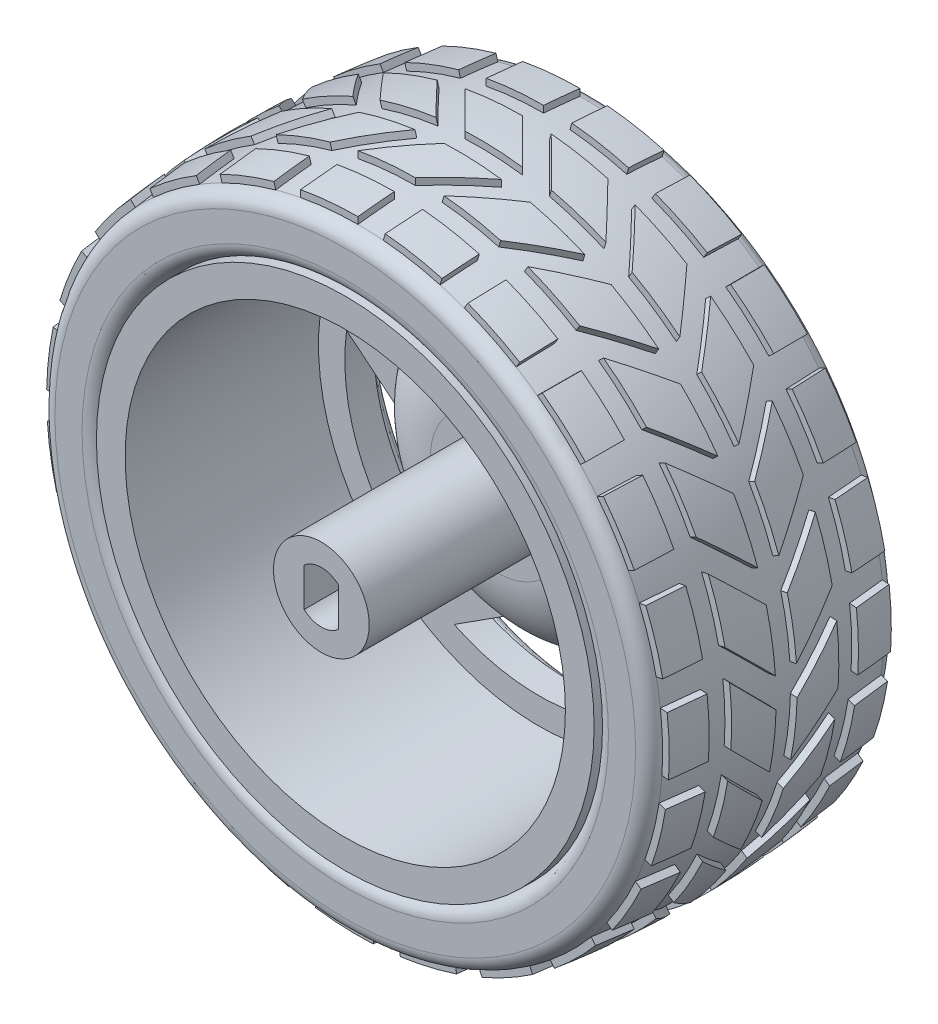
from build123d import *
from build123d.topology import SkipClean

# Parameters (mm, degrees)
CUT_EXTRUDE1_REACH  = 47.916
CIRPATTERN1_COUNT   = 5
SKETCH3_R           = 0.7500000000000007
CUT_EXTRUDE2_DEPTH  = 1
CIRPATTERN2_COUNT   = 5
SKETCH4_R           = 0.7499999999999999
BOSS_EXTRUDE1_DEPTH = 1.5
CIRPATTERN3_COUNT   = 4
FILLET1_R           = 0.75
CUT_EXTRUDE3_DEPTH  = 21.5
SKETCH6_R           = 23
SKETCH6_R_2         = 20.25
BOSS_EXTRUDE2_DEPTH = 3
FILLET2_R           = 0.5
BOSS_EXTRUDE3_REACH = 82.334
CIRPATTERN4_COUNT   = 23


with BuildPart() as part:
    # Sketch1 → Revolve1 (revolve)
    with BuildSketch(Plane(origin=(0, 0, 0), x_dir=(0, 0, -1), z_dir=(1, 0, 0)), mode=Mode.PRIVATE) as revolve1_sk:
        with BuildLine():
            Line((0, 0), (0, 5))
            Line((0, 5), (18.4, 5))
            Line((18.4, 5), (18.4, 7))
            ThreePointArc((18.4, 7), (19.547327493225943, 11.4232341109193), (22.700000000000006, 14.731106001084196))
            Line((22.700000000000006, 14.731106001084196), (22.700000000000006, 23))
            Line((22.700000000000006, 23), (2.500000000000002, 23))
            Line((2.500000000000002, 23), (2.500000000000002, 26))
            Line((2.500000000000002, 26), (29, 26))
            Line((29, 26), (28.999999999999996, 24.499999999999996))
            Line((28.999999999999996, 24.499999999999996), (28.200000000000003, 24.499999999999996))
            Line((28.200000000000003, 24.499999999999996), (28.200000000000003, 22.5))
            Line((28.200000000000003, 22.5), (25.700000000000003, 22.5))
            ThreePointArc((25.700000000000003, 22.5), (27.023630016085583, 20.96786686541544), (27.5, 19))
            Line((27.5, 19), (27.5, 12.1))
            ThreePointArc((27.5, 12.1), (23.893755415948608, 10.606244584051392), (22.4, 6.999999999999999))
            Line((22.4, 6.999999999999999), (22.400000000000002, 4.999999999999999))
            Line((22.400000000000002, 4.999999999999999), (24.5, 5))
            Line((24.5, 5), (24.5, 0))
            Line((24.5, 0), (0, 0))
        make_face()
    revolve(revolve1_sk.sketch.rotate(Axis((0, 0, 0), (0, 0, -1)), 90), axis=Axis((0, 0, 0), (0, 0, -1)))

    # Sketch2 → Cut-Extrude1 (cut, up to next)
    with BuildSketch(Plane(origin=(0, 0, -27.5), x_dir=(-1, 0, 0), z_dir=(0, 0, -1)), mode=Mode.PRIVATE) as cut_extrude1_sk1:
        with BuildLine():
            Line((-6.2937646876596895, 17.92731229315686), (-3.592234585008039, 19.89008880341997))
            Line((-3.592234585008039, 19.89008880341997), (-2.6377364584542584, 22.34485055612906))
            ThreePointArc((-2.6377364584542566, 22.34485055612906), (-13.225168176580603, 18.20288237343635), (-20.436110334703137, 9.413575005694685))
            Line((-20.436110334703134, 9.413575005694687), (-17.8065370316328, 9.562793570016428))
            Line((-17.8065370316328, 9.562793570016433), (-15.105006928980922, 11.52557008027971))
            ThreePointArc((-15.105006928980915, 11.5255700802797), (-11.167919793556816, 15.371322893124127), (-6.2937646876596265, 17.92731229315674))
        make_face()
    cut_extrude1_tool1 = extrude(cut_extrude1_sk1.sketch, amount=-CUT_EXTRUDE1_REACH, mode=Mode.PRIVATE) & part.part
    # Sketch2 → Cut-Extrude1 (cut, up to next)
    with BuildSketch(Plane(origin=(0, 0, -27.5), x_dir=(-1, 0, 0), z_dir=(0, 0, -1)), mode=Mode.PRIVATE) as cut_extrude1_sk2:
        with BuildLine():
            ThreePointArc((-4.113558593505285, 18.54935674620009), (-5.212948234450427, 18.27088313971003), (-6.2937646876596265, 17.92731229315674))
            Line((-6.2937646876596895, 17.92731229315686), (-15.105006928980922, 11.52557008027971))
            ThreePointArc((-15.105006928980915, 11.5255700802797), (-15.765752873246397, 10.60382177989252), (-16.370327093807, 9.644293174814237))
            Line((-16.370327093806985, 9.644293174814193), (-10.93911438733536, 9.952494418582303))
            ThreePointArc((-10.93911438733536, 9.952494418582301), (-7.993879431177611, 11.0026311234993), (-6.085012421085667, 13.47920593233713))
            Line((-6.085012421085668, 13.47920593233713), (-4.113558593504962, 18.549356746199816))
        make_face()
    cut_extrude1_tool2 = extrude(cut_extrude1_sk2.sketch, amount=-CUT_EXTRUDE1_REACH, mode=Mode.PRIVATE) & part.part
    # Sketch2 → Cut-Extrude1 (cut, up to next)
    with BuildSketch(Plane(origin=(0, 0, -27.5), x_dir=(-1, 0, 0), z_dir=(0, 0, -1)), mode=Mode.PRIVATE) as cut_extrude1_sk3:
        with BuildLine():
            Line((-15.105006928980922, 11.52557008027971), (-6.2937646876596895, 17.92731229315686))
            ThreePointArc((-6.2937646876596265, 17.92731229315674), (-11.167919793556816, 15.371322893124127), (-15.105006928980915, 11.5255700802797))
        make_face()
    cut_extrude1_tool3 = extrude(cut_extrude1_sk3.sketch, amount=-CUT_EXTRUDE1_REACH, mode=Mode.PRIVATE) & part.part
    # Sketch2 → Cut-Extrude1 (cut, up to next)
    with BuildSketch(Plane(origin=(0, 0, -27.5), x_dir=(-1, 0, 0), z_dir=(0, 0, -1)), mode=Mode.PRIVATE) as cut_extrude1_sk4:
        with BuildLine():
            Line((-4.113558593504962, 18.549356746199816), (-3.592234585008039, 19.89008880341997))
            Line((-3.592234585008039, 19.89008880341997), (-6.2937646876596895, 17.92731229315686))
            ThreePointArc((-6.2937646876596265, 17.92731229315674), (-5.212948234450427, 18.27088313971003), (-4.113558593505285, 18.54935674620009))
        make_face()
    cut_extrude1_tool4 = extrude(cut_extrude1_sk4.sketch, amount=-CUT_EXTRUDE1_REACH, mode=Mode.PRIVATE) & part.part
    # Sketch2 → Cut-Extrude1 (cut, up to next)
    with BuildSketch(Plane(origin=(0, 0, -27.5), x_dir=(-1, 0, 0), z_dir=(0, 0, -1)), mode=Mode.PRIVATE) as cut_extrude1_sk5:
        with BuildLine():
            ThreePointArc((-16.370327093807, 9.644293174814237), (-15.765752873246397, 10.60382177989252), (-15.105006928980915, 11.5255700802797))
            Line((-15.105006928980922, 11.52557008027971), (-17.8065370316328, 9.562793570016433))
            Line((-17.8065370316328, 9.562793570016428), (-16.370327093806985, 9.644293174814193))
        make_face()
    cut_extrude1_tool5 = extrude(cut_extrude1_sk5.sketch, amount=-CUT_EXTRUDE1_REACH, mode=Mode.PRIVATE) & part.part
    cut_extrude1_1 = cut_extrude1_tool1.solids().sort_by_distance((11.86589, 16.331997, -27.5))[0]
    add(cut_extrude1_1, mode=Mode.SUBTRACT)
    cut_extrude1_2 = cut_extrude1_tool2.solids().sort_by_distance((9.623971, 13.24626, -27.5))[0]
    add(cut_extrude1_2, mode=Mode.SUBTRACT)
    cut_extrude1_3 = cut_extrude1_tool3.solids().sort_by_distance((10.887141, 14.984863, -27.5))[0]
    add(cut_extrude1_3, mode=Mode.SUBTRACT)
    cut_extrude1_4 = cut_extrude1_tool4.solids().sort_by_distance((4.644348, 18.810956, -27.5))[0]
    add(cut_extrude1_4, mode=Mode.SUBTRACT)
    cut_extrude1_5 = cut_extrude1_tool5.solids().sort_by_distance((16.4551, 10.229942, -27.5))[0]
    add(cut_extrude1_5, mode=Mode.SUBTRACT)
    cut_extrude1 = cut_extrude1_1 + cut_extrude1_2 + cut_extrude1_3 + cut_extrude1_4 + cut_extrude1_5  # Cut-Extrude1 as one shape, for the pattern or mirror that repeats it

    # CirPattern1: Cut-Extrude1 ×5 about axis
    with SkipClean():  # the faces are left unmerged after this step: merging them gives an invalid solid
        cirpattern1_axis = Axis((-1.8e-16, 4.9e-16, 0), (0, 0, 1))
        for i in range(1, CIRPATTERN1_COUNT):
            add(cut_extrude1.rotate(cirpattern1_axis, i * 360 / CIRPATTERN1_COUNT), mode=Mode.SUBTRACT)

    # Sketch3 → Cut-Extrude2 (cut)
    with SkipClean():  # the faces are left unmerged after this step: merging them gives an invalid solid
        with BuildSketch(Plane(origin=(0, 0, -27.5), x_dir=(-1, 0, 0), z_dir=(0, 0, -1))):
            with Locations((0, 16.85)):
                Circle(SKETCH3_R)
        cut_extrude2 = extrude(amount=-CUT_EXTRUDE2_DEPTH, mode=Mode.SUBTRACT)

    # CirPattern2: Cut-Extrude2 ×5 about axis
    with SkipClean():  # the faces are left unmerged after this step: merging them gives an invalid solid
        cirpattern2_axis = Axis((-2.2e-16, 4e-17, 0), (0, 0, 1))
        for i in range(1, CIRPATTERN2_COUNT):
            add(cut_extrude2.rotate(cirpattern2_axis, i * 360 / CIRPATTERN2_COUNT), mode=Mode.SUBTRACT)

    # Sketch4 → Boss-Extrude1 (add)
    with SkipClean():  # the faces are left unmerged after this step: merging them gives an invalid solid
        with BuildSketch(Plane(origin=(0, 0, -22.400000000000002), x_dir=(-1, 0, 0), z_dir=(0, 0, -1))):
            with Locations(Location((0, 5.999999999999999, 0), (0, 0, 180))):
                Circle(SKETCH4_R)
        boss_extrude1 = extrude(amount=BOSS_EXTRUDE1_DEPTH)

    # CirPattern3: Boss-Extrude1 ×4 about axis
    with SkipClean():  # the faces are left unmerged after this step: merging them gives an invalid solid
        cirpattern3_axis = Axis((-1.047e-14, 0, 0), (0, 0, 1))
        for i in range(1, CIRPATTERN3_COUNT):
            add(boss_extrude1.rotate(cirpattern3_axis, i * 360 / CIRPATTERN3_COUNT))

    # Fillet1
    fillet1_edges = [part.edges().sort_by_distance(p)[0] for p in [
        (-0.7499999999999999, 5.999999999999999, -23.900000000000002),
        (-6.00000000000001, -0.7499999999999888, -23.900000000000002),
        (0.7499999999999781, -5.999999999999999, -23.900000000000002),
        (5.9999999999999885, 0.7499999999999881, -23.900000000000002),
    ]]
    fillet(fillet1_edges, radius=FILLET1_R)

    # Sketch5 → Cut-Extrude3 (cut)
    with SkipClean():  # the faces are left unmerged after this step: merging them gives an invalid solid
        with BuildSketch(Plane.XY):
            with BuildLine():
                ThreePointArc((1.8, 2.0124611797498106), (1.7e-16, 2.7), (-1.8000000000000003, 2.0124611797498106))
                Line((-1.8, 2.012461179749811), (-1.8, -2.012461179749811))
                ThreePointArc((-1.800000000000001, -2.01246117974981), (-5e-16, -2.7), (1.8, -2.0124611797498106))
                Line((1.8, -2.012461179749811), (1.8, 2.012461179749811))
            make_face()
        extrude(amount=-CUT_EXTRUDE3_DEPTH, mode=Mode.SUBTRACT)

    # Sketch6 → Boss-Extrude2 (add)
    with BuildSketch(Plane.XY.offset(-22.700000000000006)):
        Circle(SKETCH6_R)
        Circle(SKETCH6_R_2, mode=Mode.SUBTRACT)
    extrude(amount=-BOSS_EXTRUDE2_DEPTH)

    # Fillet2
    fillet2_edges = [part.edges().sort_by_distance(p)[0] for p in [
        (-22.5, -5.25e-15, -28.200000000000003),
        (-24.499999999999996, 5.16e-15, -28.999999999999996),
    ]]
    fillet(fillet2_edges, radius=FILLET2_R)

    # Sketch7 → Revolve2 (revolve)
    with BuildSketch(Plane(origin=(0, 0, 0), x_dir=(0, 0, -1), z_dir=(1, 0, 0)), mode=Mode.PRIVATE) as revolve2_sk:
        with BuildLine():
            Line((4, 26), (27.5, 26))
            ThreePointArc((27.5, 26), (28.122729969079412, 26.637953017521667), (28.35, 27.5))
            Line((28.35, 27.5), (28.350000000000005, 30.332267399417287))
            ThreePointArc((28.350000000000005, 30.332267399417287), (27.97073783625531, 31.32923615639299), (27.024737730152356, 31.822054876093443))
            ThreePointArc((27.024737730152356, 31.82205487609349), (15.425000000000002, 32.50000000000003), (3.8252622698476486, 31.82205487609346))
            ThreePointArc((3.8252622698476504, 31.822054876093443), (2.8792621637446962, 31.32923615639299), (2.5000000000000018, 30.332267399417287))
            Line((2.5000000000000018, 30.332267399417287), (2.500000000000002, 27.499999999999996))
            ThreePointArc((2.5000000000000027, 27.499999999999996), (2.939339828220182, 26.439339828220177), (4.000000000000002, 26))
        make_face()
    revolve(revolve2_sk.sketch.rotate(Axis((0, 0, 0), (0, 0, -1)), 90), axis=Axis((0, 0, 0), (0, 0, -1)))

    # Sketch8 → Boss-Extrude3 (add, up to next)
    with BuildSketch(Plane(origin=(0, 35, 0), x_dir=(1, 0, 0), z_dir=(0, 1, 0)), mode=Mode.PRIVATE) as boss_extrude3_sk1:
        Polygon((-6.000000000000003, 27.02473773015237), (0, 27.024737730152363), (4.7e-16, 23.225), (-5.999999999999998, 23.225), align=None)
    boss_extrude3_tool1 = extrude(boss_extrude3_sk1.sketch, amount=-BOSS_EXTRUDE3_REACH, mode=Mode.PRIVATE) - part.part
    # Sketch8 → Boss-Extrude3 (add, up to next)
    with BuildSketch(Plane(origin=(0, 35, 0), x_dir=(1, 0, 0), z_dir=(0, 1, 0)), mode=Mode.PRIVATE) as boss_extrude3_sk2:
        Polygon((0, 3.8252622698476455), (0, 7.625000000000005), (-5.999999999999998, 7.625000000000005), (-6, 3.8252622698476495), align=None)
    boss_extrude3_tool2 = extrude(boss_extrude3_sk2.sketch, amount=-BOSS_EXTRUDE3_REACH, mode=Mode.PRIVATE) - part.part
    # Sketch8 → Boss-Extrude3 (add, up to next)
    with BuildSketch(Plane(origin=(0, 35, 0), x_dir=(1, 0, 0), z_dir=(0, 1, 0)), mode=Mode.PRIVATE) as boss_extrude3_sk3:
        Polygon((-5.999999999999998, 21.02500000000001), (1.76e-15, 21.025000000000002), (4.4999999999999964, 16.525000000000006), (-1.4999999999999936, 16.525000000000006), align=None)
    boss_extrude3_tool3 = extrude(boss_extrude3_sk3.sketch, amount=-BOSS_EXTRUDE3_REACH, mode=Mode.PRIVATE) - part.part
    # Sketch8 → Boss-Extrude3 (add, up to next)
    with BuildSketch(Plane(origin=(0, 35, 0), x_dir=(1, 0, 0), z_dir=(0, 1, 0)), mode=Mode.PRIVATE) as boss_extrude3_sk4:
        Polygon((-1.4999999999999936, 14.325000000000005), (4.499999999999998, 14.325000000000005), (2.7e-16, 9.825000000000005), (-5.999999999999998, 9.825000000000008), align=None)
    boss_extrude3_tool4 = extrude(boss_extrude3_sk4.sketch, amount=-BOSS_EXTRUDE3_REACH, mode=Mode.PRIVATE) - part.part
    boss_extrude3_1 = boss_extrude3_tool1.solids().sort_by_distance((-3, 35, -25.124869))[0]
    add(boss_extrude3_1)
    boss_extrude3_2 = boss_extrude3_tool2.solids().sort_by_distance((-3, 35, -5.725131))[0]
    add(boss_extrude3_2)
    boss_extrude3_3 = boss_extrude3_tool3.solids().sort_by_distance((-0.75, 35, -18.775))[0]
    add(boss_extrude3_3)
    boss_extrude3_4 = boss_extrude3_tool4.solids().sort_by_distance((-0.75, 35, -12.075))[0]
    add(boss_extrude3_4)
    boss_extrude3 = boss_extrude3_1 + boss_extrude3_2 + boss_extrude3_3 + boss_extrude3_4  # Boss-Extrude3 as one shape, for the pattern or mirror that repeats it

    # CirPattern4: Boss-Extrude3 ×23 about axis
    cirpattern4_axis = Axis((-4.4e-16, -7.9e-16, 0), (0, 0, 1))
    for i in range(1, CIRPATTERN4_COUNT):
        add(boss_extrude3.rotate(cirpattern4_axis, i * 360 / CIRPATTERN4_COUNT))

    # Sketch9 → Cut-Revolve1 (revolve, cut)
    with BuildSketch(Plane(origin=(0, 0, 0), x_dir=(0, 0, -1), z_dir=(1, 0, 0)), mode=Mode.PRIVATE) as cut_revolve1_sk:
        with BuildLine():
            Line((2.40913934720874, 32.35167619620889), (2.40913934720874, 40.815021703130135))
            Line((2.40913934720874, 40.815021703130135), (28.440860652791255, 40.815021703130135))
            Line((28.440860652791255, 40.815021703130135), (28.440860652791255, 32.35167619620889))
            ThreePointArc((28.440860652791255, 32.35167619620889), (15.425000000000006, 33.20000000000002), (2.40913934720874, 32.35167619620889))
        make_face()
    revolve(cut_revolve1_sk.sketch.rotate(Axis((0, 0, 0), (0, 0, -1)), 270.871043315), axis=Axis((0, 0, 0), (0, 0, -1)), mode=Mode.SUBTRACT)


solid = part.part
